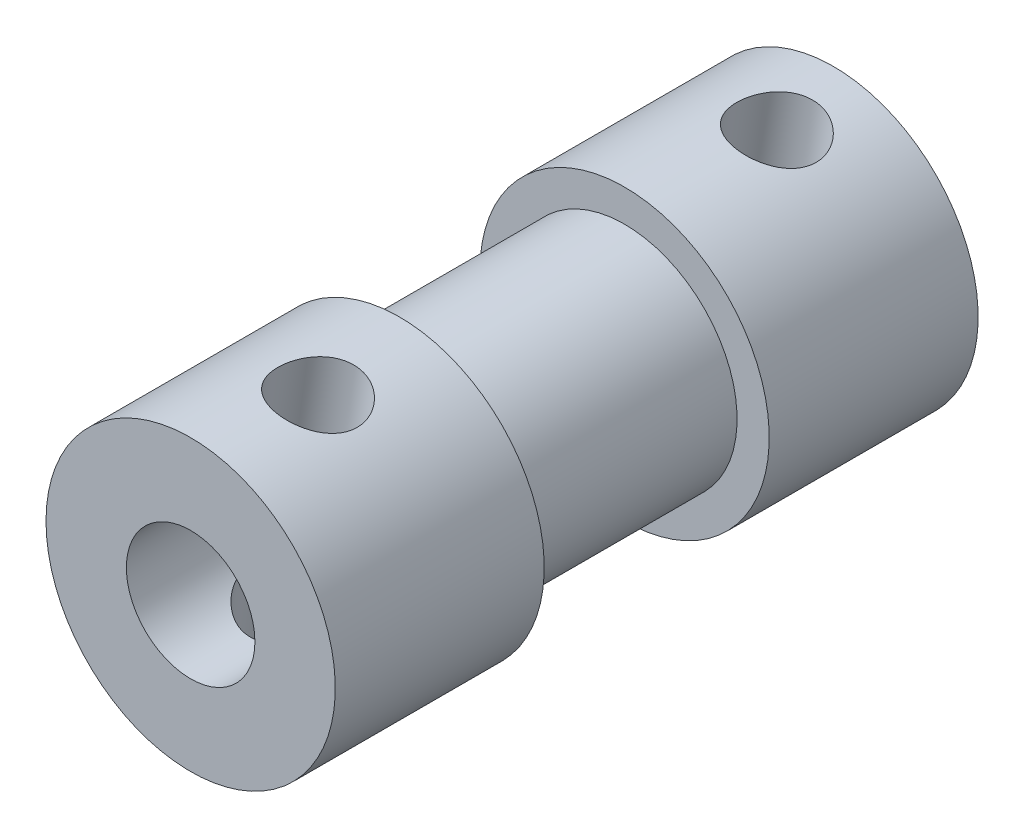
from build123d import *

# Parameters (mm, degrees)
F_4_0MM_DOWEL_HOLE1_D           = 4
M3X0_5_TAPPED_HOLE1_D           = 2.5
M3X0_5_TAPPED_HOLE1_ON_FACE_2_D = 2.5


with BuildPart() as part:
    # Sketch1 → Revolve1 (revolve)
    with BuildSketch(Plane(origin=(0, 0, 0), x_dir=(1, 0, 0), z_dir=(0, 1, 0))):
        Polygon((4.5, 10), (0, 10), (0, -10), (4.5, -10), (4.5, -3.5), (3.5, -3.5), (3.5, 3.5), (4.5, 3.5), align=None)
    revolve(axis=Axis((0, 0, -10), (0, 0, 1)))

    # Ø4.0mm Dowel Hole1 (through all)
    with Locations(Plane.XY.offset(10)):
        with Locations((0, 0)):
            Hole(F_4_0MM_DOWEL_HOLE1_D / 2)

    # M3x0.5 Tapped Hole1 (through all)
    with Locations(Plane(origin=(0.688844658, 4.446964474, 6.712810899), x_dir=(0.988214328, -0.153076591, 0), z_dir=(0.153076591, 0.988214328, 0))):
        with Locations((0, 0)):
            Hole(M3X0_5_TAPPED_HOLE1_D / 2)

    # M3x0.5 Tapped Hole1 on face 2 (through all)
    with Locations(Plane(origin=(0.688844658, 4.446964474, -7.56241821), x_dir=(0.988214258, -0.15307704, 0), z_dir=(0.15307704, 0.988214258, 0))):
        with Locations((0, 0)):
            Hole(M3X0_5_TAPPED_HOLE1_ON_FACE_2_D / 2)


solid = part.part
